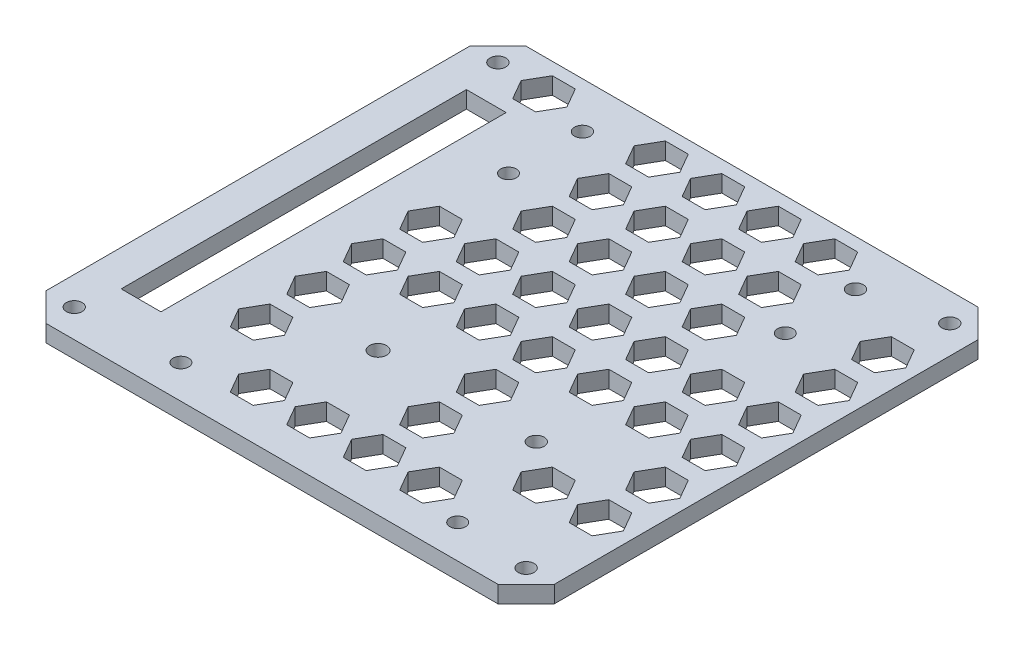
from build123d import *

# Parameters (mm, degrees)
SKETCH1_W           = 90
SKETCH1_H           = 85
SKETCH1_R           = 1.4
BOSS_EXTRUDE1_DEPTH = 3
SKETCH4_R           = 1.375
CUT_EXTRUDE1_DEPTH  = 10
SKETCH5_R           = 1.4
SKETCH5_R_2         = 1.5
CUT_EXTRUDE2_DEPTH  = 10
SKETCH6_W           = 7.040947863
SKETCH6_H           = 61.115427446
CUT_EXTRUDE3_DEPTH  = 10
CHAMFER1_SIZE       = 5
CUT_EXTRUDE4_DEPTH  = 10


with BuildPart() as part:
    # Sketch1 → Boss-Extrude1 (new body)
    with BuildSketch(Plane(origin=(0, 0, 0), x_dir=(1, 0, 0), z_dir=(0, 1, 0))):
        Rectangle(SKETCH1_W, SKETCH1_H)
        with Locations((-40, 37.5)):
            Circle(SKETCH1_R, mode=Mode.SUBTRACT)
        with Locations((40, 37.5)):
            Circle(SKETCH1_R, mode=Mode.SUBTRACT)
        with Locations((40, -37.5)):
            Circle(SKETCH1_R, mode=Mode.SUBTRACT)
        with Locations((-40, -37.5)):
            Circle(SKETCH1_R, mode=Mode.SUBTRACT)
    extrude(amount=BOSS_EXTRUDE1_DEPTH)

    # Sketch4 → Cut-Extrude1 (cut)
    with BuildSketch(Plane(origin=(0, 3, 0), x_dir=(1, 0, 0), z_dir=(0, 1, 0))):
        with Locations((26.948263012, -36.564068794)):
            Circle(SKETCH4_R)
        with Locations((-22.051736988, -36.564068794)):
            Circle(SKETCH4_R)
        with Locations((-22.051736988, 21.435931206)):
            Circle(SKETCH4_R)
        with Locations((26.948263012, 21.435931206)):
            Circle(SKETCH4_R)
    extrude(amount=-CUT_EXTRUDE1_DEPTH, mode=Mode.SUBTRACT)

    # Sketch5 → Cut-Extrude2 (cut)
    with BuildSketch(Plane(origin=(0, 0, 0), x_dir=(-1, 0, 0), z_dir=(0, -1, 0))):
        with Locations((21.911011217, 34.3776)):
            Circle(SKETCH5_R)
        with Locations((-26.425188783, 34.3776)):
            Circle(SKETCH5_R)
        with Locations((6.469503984, -17.2479)):
            Circle(SKETCH5_R_2)
        with Locations((-21.546696016, -17.2479)):
            Circle(SKETCH5_R)
    extrude(amount=-CUT_EXTRUDE2_DEPTH, mode=Mode.SUBTRACT)

    # Sketch6 → Cut-Extrude3 (cut)
    with BuildSketch(Plane(origin=(0, 3, 0), x_dir=(1, 0, 0), z_dir=(0, 1, 0))):
        with Locations((-35.112160837, 0)):
            Rectangle(SKETCH6_W, SKETCH6_H)
    extrude(amount=-CUT_EXTRUDE3_DEPTH, mode=Mode.SUBTRACT)

    # Chamfer1
    chamfer1_edges = [part.edges().sort_by_distance(p)[0] for p in [
        (45, 1.5, -42.5),
        (45, 1.5, 42.5),
        (-45, 1.5, 42.5),
        (-45, 1.5, -42.5),
    ]]
    chamfer(chamfer1_edges, length=CHAMFER1_SIZE)

    # Sketch7 → Cut-Extrude4 (cut)
    with BuildSketch(Plane(origin=(0, 3, 0), x_dir=(1, 0, 0), z_dir=(0, 1, 0))):
        Polygon((-29.087169555, 33.266336373), (-27.059204043, 36.778875674), (-29.087169555, 40.291414976), (-33.143100577, 40.291414976), (-35.171066089, 36.778875674), (-33.143100577, 33.266336373), align=None)
        Polygon((-9.087169555, 33.266336373), (-7.059204043, 36.778875674), (-9.087169555, 40.291414976), (-13.143100577, 40.291414976), (-15.171066089, 36.778875674), (-13.143100577, 33.266336373), align=None)
        Polygon((0.912830445, 33.266336373), (2.940795957, 36.778875674), (0.912830445, 40.291414976), (-3.143100577, 40.291414976), (-5.171066089, 36.778875674), (-3.143100577, 33.266336373), align=None)
        Polygon((10.912830445, 33.266336373), (12.940795957, 36.778875674), (10.912830445, 40.291414976), (6.856899423, 40.291414976), (4.828933911, 36.778875674), (6.856899423, 33.266336373), align=None)
        Polygon((20.912830445, 33.266336373), (22.940795957, 36.778875674), (20.912830445, 40.291414976), (16.856899423, 40.291414976), (14.828933911, 36.778875674), (16.856899423, 33.266336373), align=None)
        Polygon((-9.087169555, 23.266336373), (-7.059204043, 26.778875674), (-9.087169555, 30.291414976), (-13.143100577, 30.291414976), (-15.171066089, 26.778875674), (-13.143100577, 23.266336373), align=None)
        Polygon((0.912830445, 23.266336373), (2.940795957, 26.778875674), (0.912830445, 30.291414976), (-3.143100577, 30.291414976), (-5.171066089, 26.778875674), (-3.143100577, 23.266336373), align=None)
        Polygon((10.912830445, 23.266336373), (12.940795957, 26.778875674), (10.912830445, 30.291414976), (6.856899423, 30.291414976), (4.828933911, 26.778875674), (6.856899423, 23.266336373), align=None)
        Polygon((20.912830445, 23.266336373), (22.940795957, 26.778875674), (20.912830445, 30.291414976), (16.856899423, 30.291414976), (14.828933911, 26.778875674), (16.856899423, 23.266336373), align=None)
        Polygon((40.912830445, 23.266336373), (42.940795957, 26.778875674), (40.912830445, 30.291414976), (36.856899423, 30.291414976), (34.828933911, 26.778875674), (36.856899423, 23.266336373), align=None)
        Polygon((-9.087169555, 13.266336373), (-7.059204043, 16.778875674), (-9.087169555, 20.291414976), (-13.143100577, 20.291414976), (-15.171066089, 16.778875674), (-13.143100577, 13.266336373), align=None)
        Polygon((0.912830445, 13.266336373), (2.940795957, 16.778875674), (0.912830445, 20.291414976), (-3.143100577, 20.291414976), (-5.171066089, 16.778875674), (-3.143100577, 13.266336373), align=None)
        Polygon((10.912830445, 13.266336373), (12.940795957, 16.778875674), (10.912830445, 20.291414976), (6.856899423, 20.291414976), (4.828933911, 16.778875674), (6.856899423, 13.266336373), align=None)
        Polygon((20.912830445, 13.266336373), (22.940795957, 16.778875674), (20.912830445, 20.291414976), (16.856899423, 20.291414976), (14.828933911, 16.778875674), (16.856899423, 13.266336373), align=None)
        Polygon((40.912830445, 13.266336373), (42.940795957, 16.778875674), (40.912830445, 20.291414976), (36.856899423, 20.291414976), (34.828933911, 16.778875674), (36.856899423, 13.266336373), align=None)
        Polygon((-19.087169555, 3.266336373), (-17.059204043, 6.778875674), (-19.087169555, 10.291414976), (-23.143100577, 10.291414976), (-25.171066089, 6.778875674), (-23.143100577, 3.266336373), align=None)
        Polygon((-9.087169555, 3.266336373), (-7.059204043, 6.778875674), (-9.087169555, 10.291414976), (-13.143100577, 10.291414976), (-15.171066089, 6.778875674), (-13.143100577, 3.266336373), align=None)
        Polygon((0.912830445, 3.266336373), (2.940795957, 6.778875674), (0.912830445, 10.291414976), (-3.143100577, 10.291414976), (-5.171066089, 6.778875674), (-3.143100577, 3.266336373), align=None)
        Polygon((10.912830445, 3.266336373), (12.940795957, 6.778875674), (10.912830445, 10.291414976), (6.856899423, 10.291414976), (4.828933911, 6.778875674), (6.856899423, 3.266336373), align=None)
        Polygon((20.912830445, 3.266336373), (22.940795957, 6.778875674), (20.912830445, 10.291414976), (16.856899423, 10.291414976), (14.828933911, 6.778875674), (16.856899423, 3.266336373), align=None)
        Polygon((30.912830445, 3.266336373), (32.940795957, 6.778875674), (30.912830445, 10.291414976), (26.856899423, 10.291414976), (24.828933911, 6.778875674), (26.856899423, 3.266336373), align=None)
        Polygon((40.912830445, 3.266336373), (42.940795957, 6.778875674), (40.912830445, 10.291414976), (36.856899423, 10.291414976), (34.828933911, 6.778875674), (36.856899423, 3.266336373), align=None)
        Polygon((-19.087169555, -6.733663627), (-17.059204043, -3.221124326), (-19.087169555, 0.291414976), (-23.143100577, 0.291414976), (-25.171066089, -3.221124326), (-23.143100577, -6.733663627), align=None)
        Polygon((-9.087169555, -6.733663627), (-7.059204043, -3.221124326), (-9.087169555, 0.291414976), (-13.143100577, 0.291414976), (-15.171066089, -3.221124326), (-13.143100577, -6.733663627), align=None)
        Polygon((0.912830445, -6.733663627), (2.940795957, -3.221124326), (0.912830445, 0.291414976), (-3.143100577, 0.291414976), (-5.171066089, -3.221124326), (-3.143100577, -6.733663627), align=None)
        Polygon((10.912830445, -6.733663627), (12.940795957, -3.221124326), (10.912830445, 0.291414976), (6.856899423, 0.291414976), (4.828933911, -3.221124326), (6.856899423, -6.733663627), align=None)
        Polygon((20.912830445, -6.733663627), (22.940795957, -3.221124326), (20.912830445, 0.291414976), (16.856899423, 0.291414976), (14.828933911, -3.221124326), (16.856899423, -6.733663627), align=None)
        Polygon((30.912830445, -6.733663627), (32.940795957, -3.221124326), (30.912830445, 0.291414976), (26.856899423, 0.291414976), (24.828933911, -3.221124326), (26.856899423, -6.733663627), align=None)
        Polygon((40.912830445, -6.733663627), (42.940795957, -3.221124326), (40.912830445, 0.291414976), (36.856899423, 0.291414976), (34.828933911, -3.221124326), (36.856899423, -6.733663627), align=None)
        Polygon((-19.087169555, -16.733663627), (-17.059204043, -13.221124326), (-19.087169555, -9.708585024), (-23.143100577, -9.708585024), (-25.171066089, -13.221124326), (-23.143100577, -16.733663627), align=None)
        Polygon((10.912830445, -16.733663627), (12.940795957, -13.221124326), (10.912830445, -9.708585024), (6.856899423, -9.708585024), (4.828933911, -13.221124326), (6.856899423, -16.733663627), align=None)
        Polygon((40.912830445, -16.733663627), (42.940795957, -13.221124326), (40.912830445, -9.708585024), (36.856899423, -9.708585024), (34.828933911, -13.221124326), (36.856899423, -16.733663627), align=None)
        Polygon((-19.087169555, -26.733663627), (-17.059204043, -23.221124326), (-19.087169555, -19.708585024), (-23.143100577, -19.708585024), (-25.171066089, -23.221124326), (-23.143100577, -26.733663627), align=None)
        Polygon((10.912830445, -26.733663627), (12.940795957, -23.221124326), (10.912830445, -19.708585024), (6.856899423, -19.708585024), (4.828933911, -23.221124326), (6.856899423, -26.733663627), align=None)
        Polygon((30.912830445, -26.733663627), (32.940795957, -23.221124326), (30.912830445, -19.708585024), (26.856899423, -19.708585024), (24.828933911, -23.221124326), (26.856899423, -26.733663627), align=None)
        Polygon((40.912830445, -26.733663627), (42.940795957, -23.221124326), (40.912830445, -19.708585024), (36.856899423, -19.708585024), (34.828933911, -23.221124326), (36.856899423, -26.733663627), align=None)
        Polygon((-9.087169555, -36.733663627), (-7.059204043, -33.221124326), (-9.087169555, -29.708585024), (-13.143100577, -29.708585024), (-15.171066089, -33.221124326), (-13.143100577, -36.733663627), align=None)
        Polygon((0.912830445, -36.733663627), (2.940795957, -33.221124326), (0.912830445, -29.708585024), (-3.143100577, -29.708585024), (-5.171066089, -33.221124326), (-3.143100577, -36.733663627), align=None)
        Polygon((10.912830445, -36.733663627), (12.940795957, -33.221124326), (10.912830445, -29.708585024), (6.856899423, -29.708585024), (4.828933911, -33.221124326), (6.856899423, -36.733663627), align=None)
        Polygon((20.912830445, -36.733663627), (22.940795957, -33.221124326), (20.912830445, -29.708585024), (16.856899423, -29.708585024), (14.828933911, -33.221124326), (16.856899423, -36.733663627), align=None)
    extrude(amount=-CUT_EXTRUDE4_DEPTH, mode=Mode.SUBTRACT)


solid = part.part
